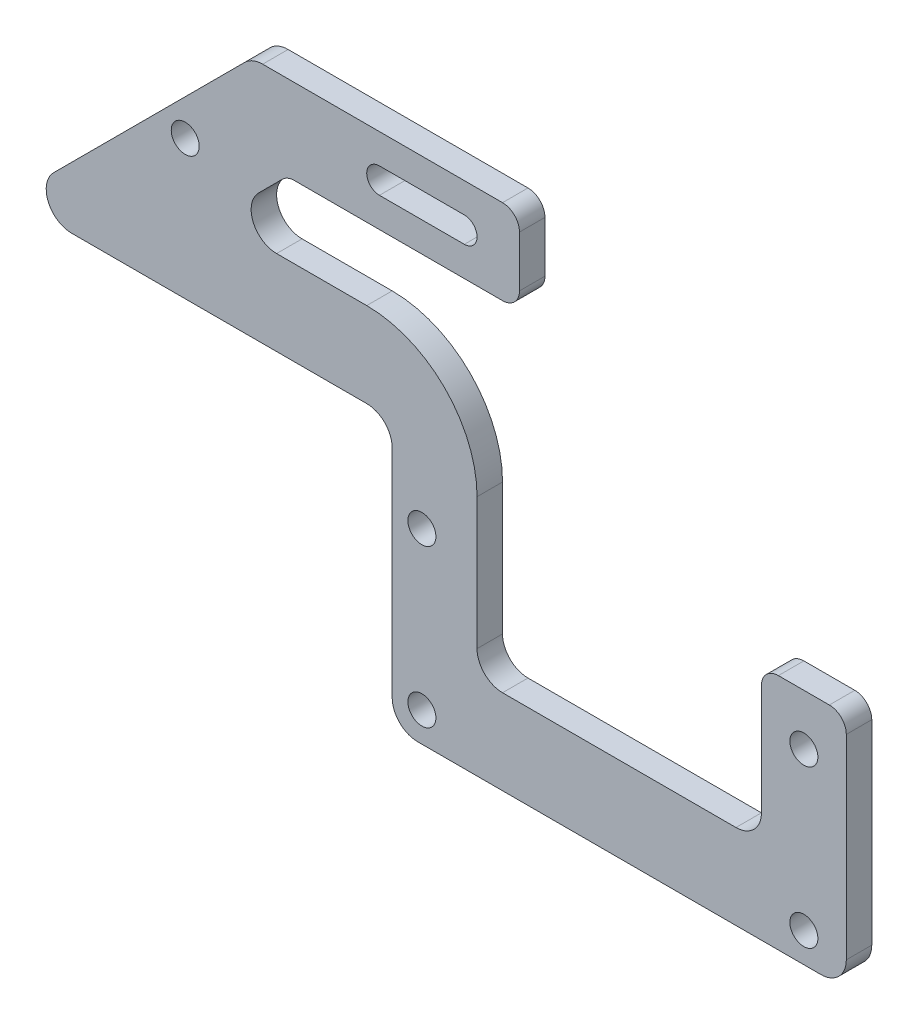
from build123d import *

# Parameters (mm, degrees)
SKETCH_1_W          = 55
SKETCH_1_H          = 30
SKETCH_1_R          = 1.65
EXTRUDE_1_DEPTH     = 3
SKETCH_2_W          = 55
SKETCH_2_H          = 30
EXTRUDE_2_DEPTH     = 3
EXTRUDE_3_DEPTH     = 3
SKETCH_8_R          = 1.65
CUT_EXTRUDE_1_DEPTH = 10
FILLET_2_R          = 3
CUT_EXTRUDE_2_DEPTH = 10
CUT_EXTRUDE_3_DEPTH = 92.964667128
FILLET_3_R          = 3
CUT_EXTRUDE_4_DEPTH = 88.508828254
FILLET_4_R          = 3
SKETCH_14_W         = 50
SKETCH_14_H         = 32
CUT_EXTRUDE_5_DEPTH = 88.508828254
FILLET_5_R          = 2


with BuildPart() as part:
    # 草图1 → 凸台-拉伸1 (new body)
    with BuildSketch(Plane.XY):
        with Locations((0, 11.5)):
            Rectangle(SKETCH_1_W, SKETCH_1_H)
        with Locations((-22.5, 0)):
            Circle(SKETCH_1_R, mode=Mode.SUBTRACT)
        with Locations((-22.5, 18.5)):
            Circle(SKETCH_1_R, mode=Mode.SUBTRACT)
        with Locations(Location((22.5, 18.5, 0), (0, 0, 180))):
            Circle(SKETCH_1_R, mode=Mode.SUBTRACT)
        with Locations(Location((22.5, 0, 0), (0, 0, 180))):
            Circle(SKETCH_1_R, mode=Mode.SUBTRACT)
    extrude(amount=EXTRUDE_1_DEPTH)

    # 草图2 → 凸台-拉伸2 (add)
    with BuildSketch(Plane.XY.offset(3)):
        with Locations((0, 41.5)):
            Rectangle(SKETCH_2_W, SKETCH_2_H)
    extrude(amount=-EXTRUDE_2_DEPTH)

    # 草图4 → 凸台-拉伸3 (add)
    with BuildSketch(Plane.XY.offset(3)):
        Polygon((-27.5, 26.5), (-72.5, 26.5), (-42.5, 56.5), (-27.5, 56.5), align=None)
    extrude(amount=-EXTRUDE_3_DEPTH)

    # 草图8 → 切除-拉伸1 (cut)
    with BuildSketch(Plane(origin=(0, 0, 0), x_dir=(-1, 0, 0), z_dir=(0, 0, -1))):
        with Locations((50.378679656, 44.378679656)):
            Circle(SKETCH_8_R)
    extrude(amount=-CUT_EXTRUDE_1_DEPTH, mode=Mode.SUBTRACT)

    # 圆角2
    fillet_2_edges = [part.edges().sort_by_distance(p)[0] for p in [
        (27.5, 56.5, 1.5),
        (-42.5, 56.5, 1.5),
        (27.5, -3.5, 1.5),
    ]]
    fillet(fillet_2_edges, radius=FILLET_2_R)

    # 草图9 → 切除-拉伸2 (cut)
    with BuildSketch(Plane.XY.offset(3)):
        with BuildLine():
            Line((-27.5, 53), (-17.5, 53))
            ThreePointArc((-17.5, 53), (-16, 51.5), (-17.5, 50))
            Line((-17.5, 50), (-27.5, 50))
            ThreePointArc((-27.5, 50), (-29, 51.5), (-27.5, 53))
        make_face()
    extrude(amount=-CUT_EXTRUDE_2_DEPTH, mode=Mode.SUBTRACT)

    # 草图12 → 切除-拉伸3 (cut, through all)
    with BuildSketch(Plane(origin=(0, 0, 0), x_dir=(-1, 0, 0), z_dir=(0, 0, -1))):
        Polygon((71, 28), (26, 28), (26, -3.5), (27.5, -3.5), (27.5, 26.5), (72.5, 26.5), align=None)
    extrude(amount=-CUT_EXTRUDE_3_DEPTH, mode=Mode.SUBTRACT)

    # 圆角3
    fillet_3_edges = [part.edges().sort_by_distance(p)[0] for p in [
        (-26, -3.5, 1.5),
        (-26, 28, 1.5),
        (-71, 28, 1.5),
    ]]
    fillet(fillet_3_edges, radius=FILLET_3_R)

    # 草图13 → 切除-拉伸4 (cut, through all)
    with BuildSketch(Plane(origin=(0, 0, 0), x_dir=(-1, 0, 0), z_dir=(0, 0, -1))):
        with BuildLine():
            Line((29, 38), (46.857864376, 38))
            Line((46.857864376, 38), (38.357864376, 46.5))
            Line((38.357864376, 46.5), (-17.5, 46.5))
            Line((-17.5, 46.5), (-17.5, 6.5))
            Line((-17.5, 6.5), (16, 6.5))
            Line((16, 6.5), (16, 25))
            ThreePointArc((16, 25), (19.807611845, 34.192388155), (29, 38))
        make_face()
    extrude(amount=-CUT_EXTRUDE_4_DEPTH, mode=Mode.SUBTRACT)

    # 圆角4
    fillet_4_edges = [part.edges().sort_by_distance(p)[0] for p in [
        (-16, 6.5, 1.5),
        (17.5, 6.5, 1.5),
        (17.5, 46.5, 1.5),
        (-46.857864376, 38, 1.5),
    ]]
    fillet(fillet_4_edges, radius=FILLET_4_R)

    # 草图14 → 切除-拉伸5 (cut, through all)
    with BuildSketch(Plane(origin=(0, 0, 0), x_dir=(-1, 0, 0), z_dir=(0, 0, -1))):
        with Locations((-14, 40.5)):
            Rectangle(SKETCH_14_W, SKETCH_14_H)
    extrude(amount=-CUT_EXTRUDE_5_DEPTH, mode=Mode.SUBTRACT)

    # 圆角5
    fillet_5_edges = [part.edges().sort_by_distance(p)[0] for p in [
        (-38.357864376, 46.5, 1.5),
        (-11, 46.5, 1.5),
        (17.5, 24.5, 1.5),
        (27.5, 24.5, 1.5),
        (-11, 56.5, 1.5),
    ]]
    fillet(fillet_5_edges, radius=FILLET_5_R)


solid = part.part
